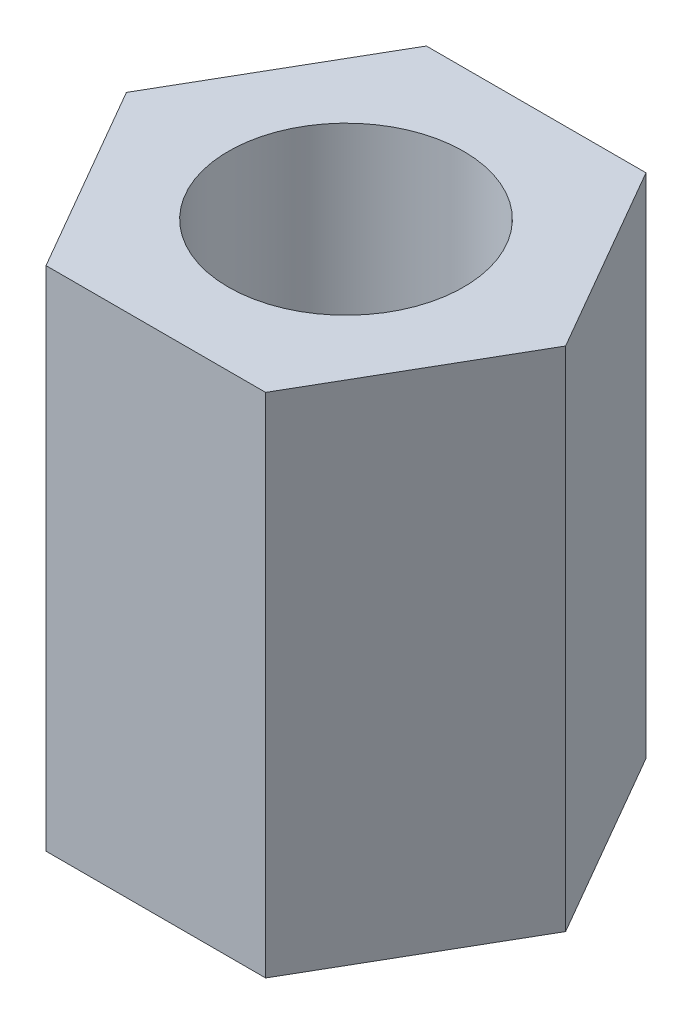
from build123d import *

# Parameters (mm, degrees)
SKETCH1_R           = 1.4732
BOSS_EXTRUDE1_DEPTH = 6.35


with BuildPart() as part:
    # Sketch1 → Boss-Extrude1 (new body)
    with BuildSketch(Plane(origin=(0, 0, 0), x_dir=(1, 0, 0), z_dir=(0, 1, 0))):
        Polygon((-2.749630657, 0), (-1.374815329, 2.38125), (1.374815329, 2.38125), (2.749630657, 0), (1.374815329, -2.38125), (-1.374815329, -2.38125), align=None)
        Circle(SKETCH1_R, mode=Mode.SUBTRACT)
    extrude(amount=BOSS_EXTRUDE1_DEPTH)


solid = part.part
